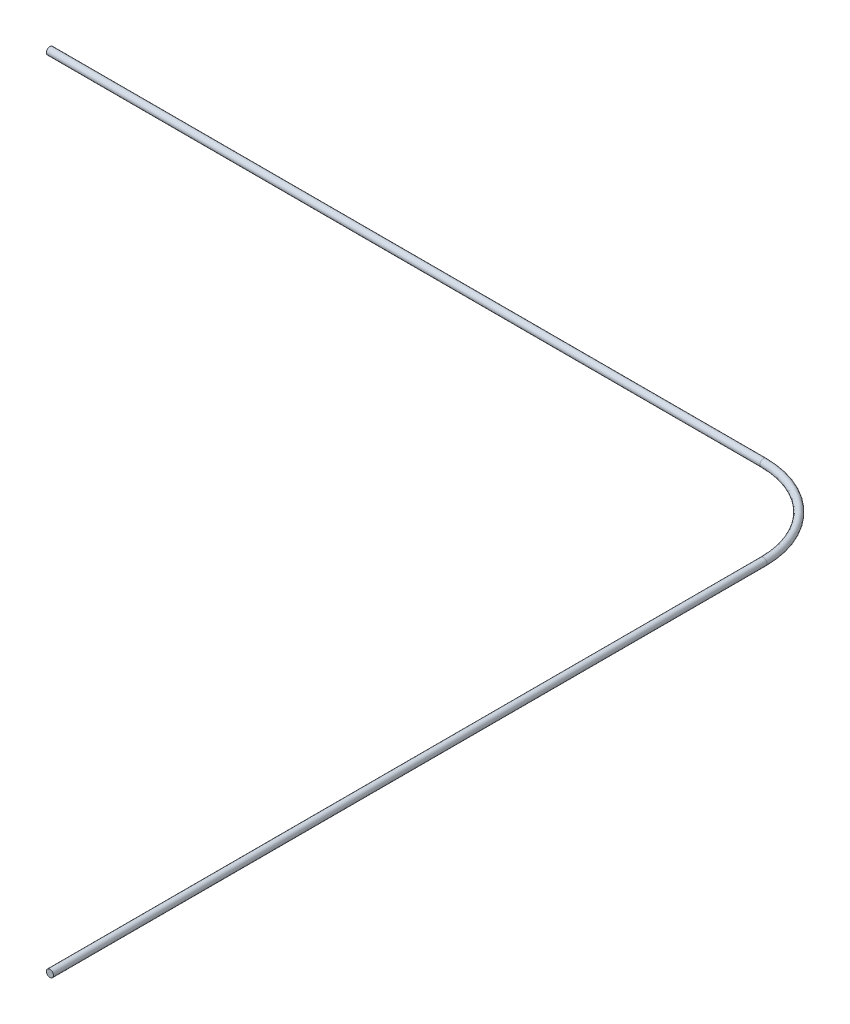
from build123d import *

# Parameters (mm, degrees)
SWEEP1_PROFILE_R = 0.25


with BuildPart() as part:
    # Sweep1: sweep along a path in Sketch1
    with BuildLine(Plane(origin=(0, 0, 0), x_dir=(1, 0, 0), z_dir=(0, 1, 0))) as sweep1_path:
        Line((-50, 6), (0, 6))
        ThreePointArc((0, 6), (4.242640687, 4.242640687), (6, 0))
        Line((6, 0), (6, -50))
    # Sweep1 profile (on start of the path) → Sweep1 (sweep)
    with BuildSketch(Plane(origin=(-50, 0, -6), x_dir=(0, 0, 1), z_dir=(1, 0, 0))):
        Circle(SWEEP1_PROFILE_R)
    sweep(path=sweep1_path.line)


solid = part.part
